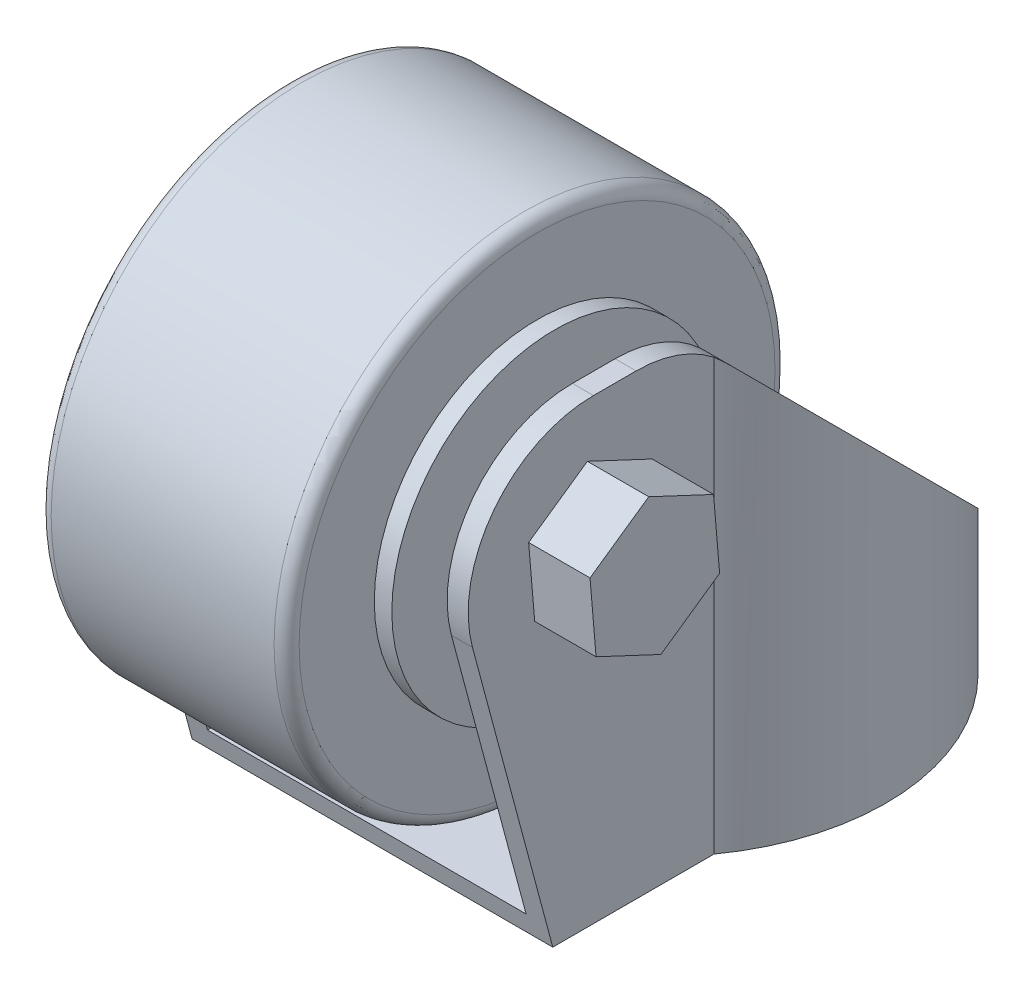
from build123d import *

# Parameters (mm, degrees)
EXTRUDE_1_DEPTH       = 1.68
SKETCH_2_R            = 14.75
EXTRUDE_3_DEPTH       = 5
EXTRUDE_4_DEPTH       = 1.68
EXTRUDE_5_DEPTH       = 40
CUT_EXTRUDE_1_DEPTH   = 30
FILLET_1_R            = 10
SKETCH_6_R            = 20
EXTRUDE_6_DEPTH       = 9.9
SKETCH_7_R            = 13
EXTRUDE_7_DEPTH       = 11.3
EXTRUDE_8_DEPTH       = 19.3
FILLET_2_R            = 1
SKETCH_9_W            = 67.955976502
SKETCH_9_H            = 118.115360496
CUT_EXTRUDE_1_2_DEPTH = 6.68


with BuildPart() as part:
    # 草图1 → 凸台-拉伸1 (new body)
    with BuildSketch(Plane(origin=(0, 0, 0), x_dir=(1, 0, 0), z_dir=(0, 1, 0))):
        with BuildLine():
            ThreePointArc((-21.5, 23.6), (-19.6254834, 28.1254834), (-15.1, 30))
            Line((-15.1, 30), (15.1, 30))
            ThreePointArc((15.1, 30), (19.6254834, 28.1254834), (21.5, 23.6))
            Line((21.5, 23.6), (21.5, -23.6))
            ThreePointArc((21.5, -23.6), (19.6254834, -28.1254834), (15.1, -30))
            Line((15.1, -30), (-15.1, -30))
            ThreePointArc((-15.1, -30), (-19.6254834, -28.1254834), (-21.5, -23.6))
            Line((-21.5, -23.6), (-21.5, 23.6))
        make_face()
        with BuildLine():
            ThreePointArc((-18.2, -23.95), (-15, -27.15), (-11.8, -23.95))
            Line((-11.8, -23.95), (-11.8, -21.05))
            ThreePointArc((-11.8, -21.05), (-15, -17.85), (-18.2, -21.05))
            Line((-18.2, -21.05), (-18.2, -23.95))
        make_face(mode=Mode.SUBTRACT)
        with BuildLine():
            ThreePointArc((18.2, -21.05), (15, -17.85), (11.8, -21.05))
            Line((11.8, -21.05), (11.8, -23.95))
            ThreePointArc((11.8, -23.95), (15, -27.15), (18.2, -23.95))
            Line((18.2, -23.95), (18.2, -21.05))
        make_face(mode=Mode.SUBTRACT)
        with BuildLine():
            ThreePointArc((18.2, 23.95), (15, 27.15), (11.8, 23.95))
            Line((11.8, 23.95), (11.8, 21.05))
            ThreePointArc((11.8, 21.05), (15, 17.85), (18.2, 21.05))
            Line((18.2, 21.05), (18.2, 23.95))
        make_face(mode=Mode.SUBTRACT)
        with BuildLine():
            ThreePointArc((-18.2, 21.05), (-15, 17.85), (-11.8, 21.05))
            Line((-11.8, 21.05), (-11.8, 23.95))
            ThreePointArc((-11.8, 23.95), (-15, 27.15), (-18.2, 23.95))
            Line((-18.2, 23.95), (-18.2, 21.05))
        make_face(mode=Mode.SUBTRACT)
    extrude(amount=EXTRUDE_1_DEPTH)

    # 草图2 → 凸台-拉伸3 (add)
    with BuildSketch(Plane(origin=(0, 1.68, 0), x_dir=(1, 0, 0), z_dir=(0, 1, 0))):
        Circle(SKETCH_2_R)
    extrude(amount=EXTRUDE_3_DEPTH)

    # 草图3 → 凸台-拉伸4 (add)
    with BuildSketch(Plane(origin=(0, 6.68, 0), x_dir=(1, 0, 0), z_dir=(0, 1, 0))):
        with BuildLine():
            Line((-14.4, -10.377981499), (-14.4, -50))
            Line((-14.4, -50), (14.4, -50))
            Line((14.4, -50), (14.4, -10.377981499))
            ThreePointArc((14.4, -10.377981499), (0, 17.75), (-14.4, -10.377981499))
        make_face()
    extrude(amount=EXTRUDE_4_DEPTH)

    # 草图4 → 凸台-拉伸5 (add)
    with BuildSketch(Plane(origin=(0, 8.36, 0), x_dir=(1, 0, 0), z_dir=(0, 1, 0))):
        with BuildLine():
            Line((-14.4, -50), (-12.72, -50))
            Line((-12.72, -50), (-12.72, -9.820717896))
            ThreePointArc((-12.72, -9.820717896), (0, 16.07), (12.72, -9.820717896))
            Line((12.72, -9.820717896), (12.72, -50))
            Line((12.72, -50), (14.4, -50))
            Line((14.4, -50), (14.4, -10.377981499))
            ThreePointArc((14.4, -10.377981499), (0, 17.75), (-14.4, -10.377981499))
            Line((-14.4, -10.377981499), (-14.4, -50))
        make_face()
    extrude(amount=EXTRUDE_5_DEPTH)

    # 草图5 → Cut-Extrude 1 (cut, symmetric)
    with BuildSketch(Plane(origin=(0, 0, 0), x_dir=(0, 0, -1), z_dir=(1, 0, 0))):
        Polygon((24.967425324, 5.782574676), (-12.45, 43.2), (-33.035504508, 43.2), (-22.754734371, 4.83164351), (-61.391767423, -5.521118294), (-85.164519421, 83.2), (4.118542495, 83.2), (53.251696571, 34.066845924), align=None)
    extrude(amount=CUT_EXTRUDE_1_DEPTH, both=True, mode=Mode.SUBTRACT)

    # 圆角1
    fillet_1_edges = [part.edges().sort_by_distance(p)[0] for p in [
        (-13.56, 43.2, 33.035504508),
        (-13.56, 43.2, 12.45),
        (13.56, 43.2, 12.45),
        (13.56, 43.2, 33.035504508),
    ]]
    fillet(fillet_1_edges, radius=FILLET_1_R)



with BuildPart() as body_2:
    # 草图6 → 凸台-拉伸6 (new body, symmetric)
    with BuildSketch(Plane(origin=(0, 0, 0), x_dir=(0, 0, -1), z_dir=(1, 0, 0))):
        with Locations((-20.003250779, 33.2)):
            Circle(SKETCH_6_R)
    extrude(amount=EXTRUDE_6_DEPTH, both=True)

    # 草图7 → 凸台-拉伸7 (add, symmetric)
    with BuildSketch(Plane(origin=(0, 0, 0), x_dir=(0, 0, -1), z_dir=(1, 0, 0))):
        with Locations((-20.003250779, 33.2)):
            Circle(SKETCH_7_R)
    extrude(amount=EXTRUDE_7_DEPTH, both=True)


with BuildPart() as part_1:
    add(part.part)

    add(body_2.part)  # 凸台-拉伸8 merges body 2
    # 草图8 → 凸台-拉伸8 (add, symmetric)
    with BuildSketch(Plane(origin=(0, 0, 0), x_dir=(0, 0, -1), z_dir=(1, 0, 0))):
        Polygon((-24.693031377, 29.932591556), (-19.518482361, 27.504826642), (-14.828701763, 30.772235086), (-15.313470181, 36.467408444), (-20.488019197, 38.895173358), (-25.177799795, 35.627764914), align=None)
    extrude(amount=EXTRUDE_8_DEPTH, both=True)

    # 圆角2
    fillet_2_edges = [part_1.edges().sort_by_distance(p)[0] for p in [
        (-9.9, 33.2, 40.003250779),
        (9.9, 33.2, 40.003250779),
    ]]
    fillet(fillet_2_edges, radius=FILLET_2_R)

    # 草图9 → Cut-Extrude 1 2 (cut)
    with BuildSketch(Plane.XZ):
        Rectangle(SKETCH_9_W, SKETCH_9_H)
    extrude(amount=-CUT_EXTRUDE_1_2_DEPTH, mode=Mode.SUBTRACT)


solid = part_1.part
